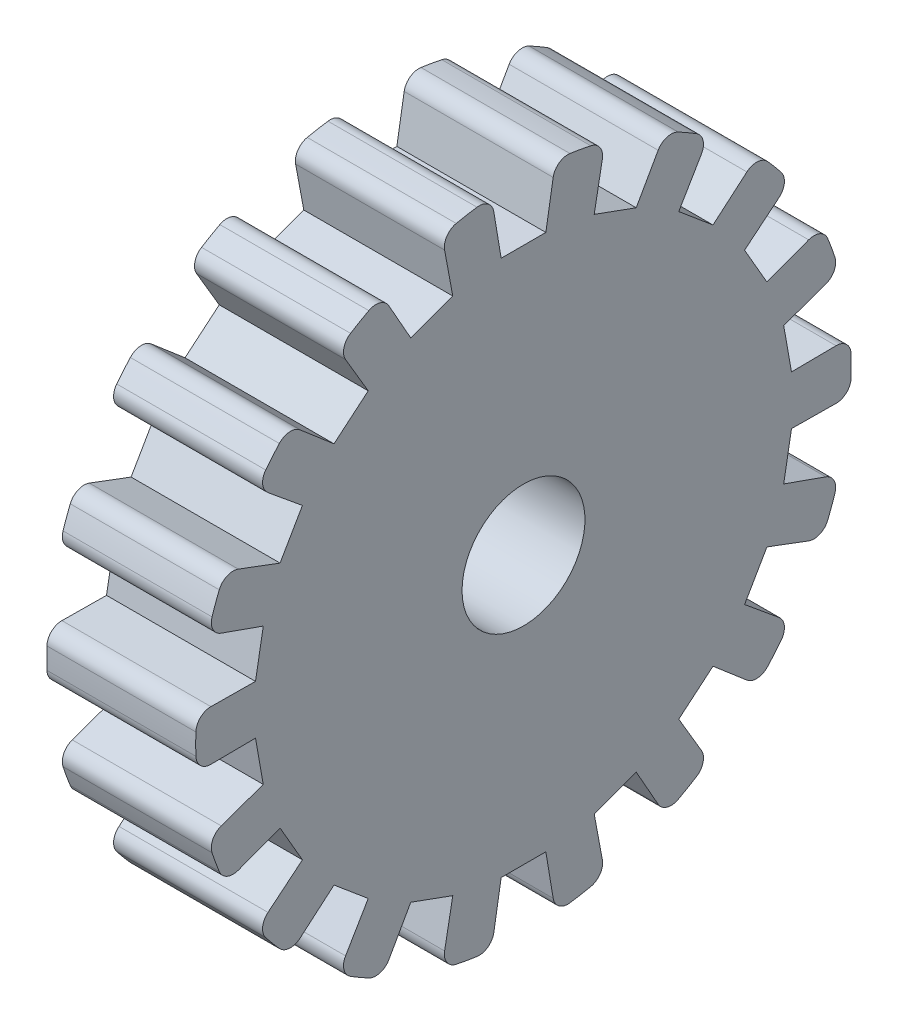
from build123d import *

# Parameters (mm, degrees)
CUT_EXTRUDE1_DEPTH       = 44
FILLET1_R                = 1
CIRPATTERN1_COUNT        = 18
FILLET1_OF_CIRPATTERN1_R = 1
SKETCH4_R                = 4.125
CUT_EXTRUDE2_DEPTH       = 10


with BuildPart() as part:
    # Sketch1 → Revolve1 (revolve)
    with BuildSketch(Plane.XY):
        Polygon((0, 0), (-10, 0), (-10, 5), (-10, 12), (-10, 22), (0, 22), (0, 20), (0, 5), align=None)
    revolve(axis=Axis((0, 0, 0), (-1, 0, 0)))

    # Sketch2 → Cut-Extrude1 (cut)
    with BuildSketch(Plane(origin=(0, 0, 0), x_dir=(0, 0, -1), z_dir=(1, 0, 0))):
        Polygon((-2.5, 24), (2.5, 24), (1.5, 18), (-1.5, 18), align=None)
    cut_extrude1 = extrude(amount=-CUT_EXTRUDE1_DEPTH, mode=Mode.SUBTRACT)

    # Fillet1
    fillet1_edges = [part.edges().sort_by_distance(p)[0] for p in [
        (-5, 21.894776607, -2.149129435),
        (-5, 21.894776607, 2.149129435),
    ]]
    fillet(fillet1_edges, radius=FILLET1_R)

    # CirPattern1: Cut-Extrude1 ×18 about axis
    cirpattern1_axis = Axis((0, 0, 0), (1, 0, 0))
    for i in range(1, CIRPATTERN1_COUNT):
        add(cut_extrude1.rotate(cirpattern1_axis, i * 360 / CIRPATTERN1_COUNT), mode=Mode.SUBTRACT)

    # Fillet1 of CirPattern1
    fillet1_of_cirpattern1_edges = [part.edges().sort_by_distance(p)[0] for p in [
        (-5, 21.309405569, 5.468933563),
        (-5, 19.839314454, 9.507975704),
        (-5, 18.153805725, 12.427362459),
        (-5, 15.390938181, 15.720019781),
        (-5, 12.80858899, 17.886868035),
        (-5, 9.086187617, 20.035997469),
        (-5, 5.918467388, 21.188953343),
        (-5, 1.685508729, 21.935338163),
        (-5, -1.685508729, 21.935338163),
        (-5, -5.918467388, 21.188953343),
        (-5, -9.086187617, 20.035997469),
        (-5, -12.80858899, 17.886868035),
        (-5, -15.390938181, 15.720019781),
        (-5, -18.153805725, 12.427362459),
        (-5, -19.839314454, 9.507975704),
        (-5, -21.309405569, 5.468933563),
        (-5, -21.894776607, 2.149129435),
        (-5, -21.894776607, -2.149129435),
        (-5, -21.309405569, -5.468933563),
        (-5, -19.839314454, -9.507975704),
        (-5, -18.153805725, -12.427362459),
        (-5, -15.390938181, -15.720019781),
        (-5, -12.80858899, -17.886868035),
        (-5, -9.086187617, -20.035997469),
        (-5, -5.918467388, -21.188953343),
        (-5, -1.685508729, -21.935338163),
        (-5, 1.685508729, -21.935338163),
        (-5, 5.918467388, -21.188953343),
        (-5, 9.086187617, -20.035997469),
        (-5, 12.80858899, -17.886868035),
        (-5, 15.390938181, -15.720019781),
        (-5, 18.153805725, -12.427362459),
        (-5, 19.839314454, -9.507975704),
        (-5, 21.309405569, -5.468933563),
    ]]
    fillet(fillet1_of_cirpattern1_edges, radius=FILLET1_OF_CIRPATTERN1_R)

    # Sketch4 → Cut-Extrude2 (cut)
    with BuildSketch(Plane.ZY.offset(10)):
        Circle(SKETCH4_R)
    extrude(amount=-CUT_EXTRUDE2_DEPTH, mode=Mode.SUBTRACT)


solid = part.part
